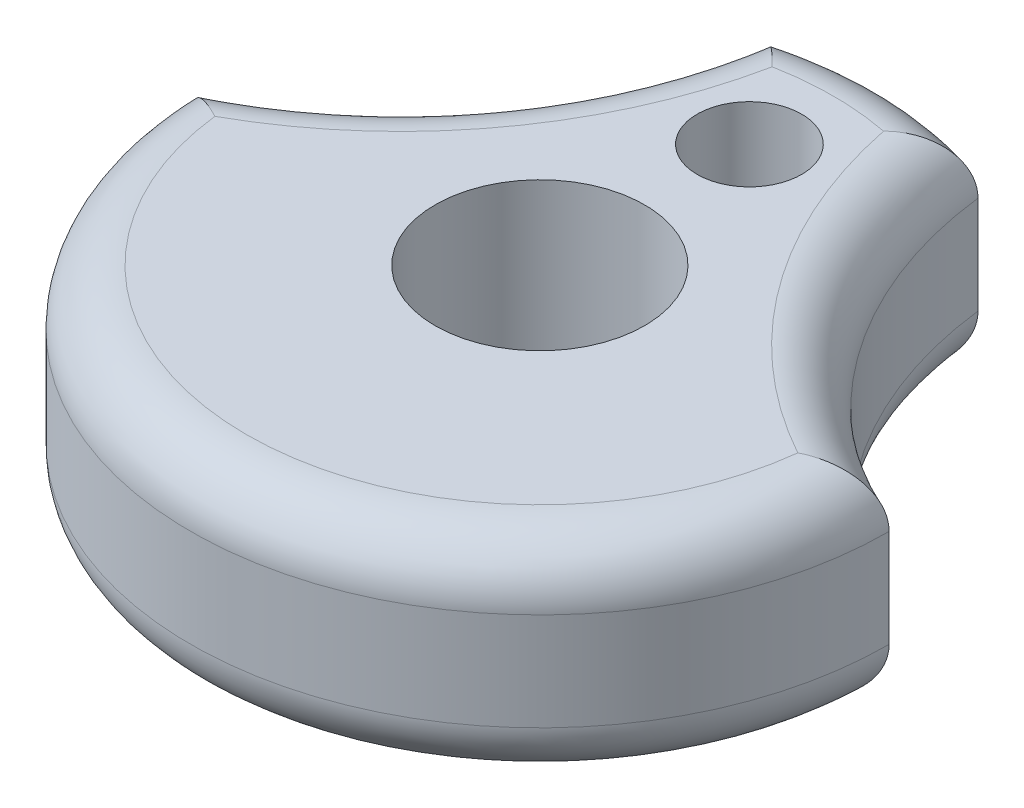
from build123d import *

# Parameters (mm, degrees)
SKETCH1_R           = 4.7625
SKETCH1_R_2         = 2.3749
BOSS_EXTRUDE1_DEPTH = 4.7625
FILLET1_R           = 2.54


with BuildPart() as part:
    # Sketch1 → Boss-Extrude1 (new body, symmetric)
    with BuildSketch(Plane(origin=(0, 0, 0), x_dir=(1, 0, 0), z_dir=(0, 1, 0))):
        with BuildLine():
            ThreePointArc((-15.875, 0), (0, -15.875), (15.875, 0))
            ThreePointArc((15.875, 0), (8.330712377, 6.107698439), (4.7752, 15.139785004))
            ThreePointArc((4.7752, 15.139785004), (0, 15.875), (-4.7752, 15.139785004))
            ThreePointArc((-4.7752, 15.139785004), (-8.330712377, 6.107698439), (-15.875, 0))
        make_face()
        Circle(SKETCH1_R, mode=Mode.SUBTRACT)
        with Locations((0, 9.525)):
            Circle(SKETCH1_R_2, mode=Mode.SUBTRACT)
    extrude(amount=BOSS_EXTRUDE1_DEPTH, both=True)

    # Fillet1
    fillet1_edges = [part.edges().sort_by_distance(p)[0] for p in [
        (0, 4.7625, 15.875),
        (8.330712377, 4.7625, -6.107698439),
        (0, 4.7625, -15.875),
        (8.330712377, -4.7625, -6.107698439),
        (0, -4.7625, 15.875),
        (-8.330712377, -4.7625, -6.107698439),
        (0, -4.7625, -15.875),
        (-8.330712377, 4.7625, -6.107698439),
    ]]
    fillet(fillet1_edges, radius=FILLET1_R)


solid = part.part
